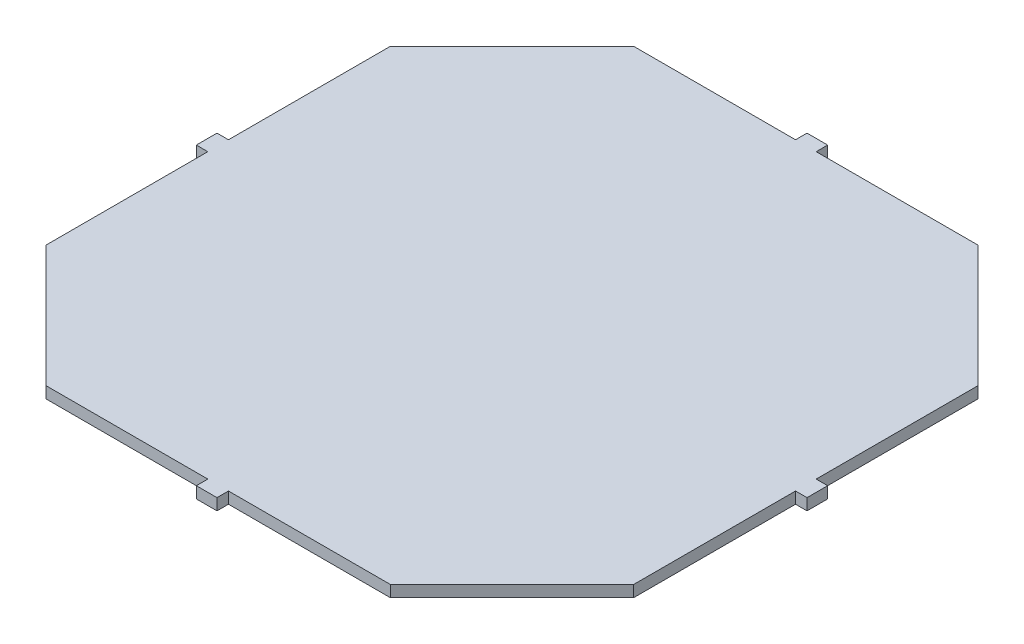
from build123d import *

# Parameters (mm, degrees)
BOSS_EXTRUDE1_DEPTH = 1
SKETCH2_W           = 1
SKETCH2_H           = 1.8
SKETCH2_W_2         = 1.8
SKETCH2_H_2         = 1
BOSS_EXTRUDE2_DEPTH = 1


with BuildPart() as part:
    # Sketch1 → Boss-Extrude1 (new body)
    with BuildSketch(Plane(origin=(0, 0, 0), x_dir=(1, 0, 0), z_dir=(0, 1, 0))):
        Polygon((-25.606601718, 15), (-15, 25.606601718), (15, 25.606601718), (25.606601718, 15), (25.606601718, -15), (15, -25.606601718), (-15, -25.606601718), (-25.606601718, -15), align=None)
    extrude(amount=BOSS_EXTRUDE1_DEPTH)

    # Sketch2 → Boss-Extrude2 (add)
    with BuildSketch(Plane(origin=(0, 1, 0), x_dir=(1, 0, 0), z_dir=(0, 1, 0))):
        with Locations((-26.106601718, 0)):
            Rectangle(SKETCH2_W, SKETCH2_H)
        with Locations((0, 26.106601718)):
            Rectangle(SKETCH2_W_2, SKETCH2_H_2)
        with Locations((0, -26.106601718)):
            Rectangle(SKETCH2_W_2, SKETCH2_H_2)
        with Locations((26.106601718, 0)):
            Rectangle(SKETCH2_W, SKETCH2_H)
    extrude(amount=-BOSS_EXTRUDE2_DEPTH)


solid = part.part
